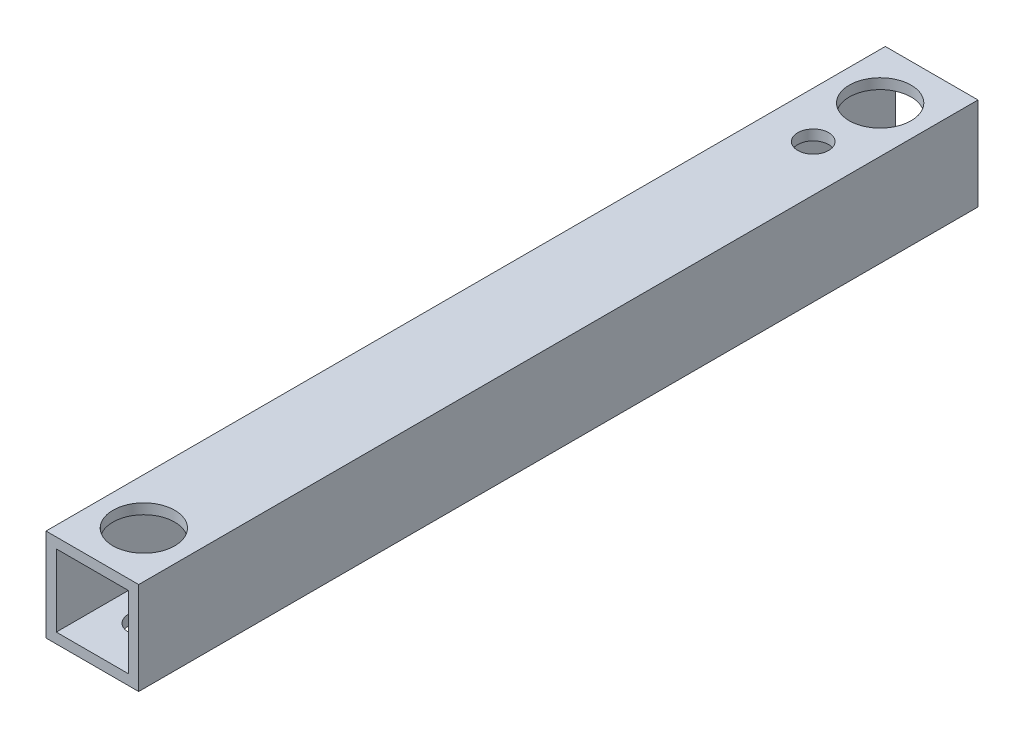
from build123d import *

# Parameters (mm, degrees)
SKETCH_1_W          = 9
SKETCH_1_H          = 9
EXTRUDE_1_DEPTH     = 81.5
SKETCH_2_W          = 7
SKETCH_2_H          = 7
CUT_EXTRUDE_1_DEPTH = 101.5
SKETCH_3_R          = 3
SKETCH_3_R_2        = 1.5
CUT_EXTRUDE_2_DEPTH = 111.5
SKETCH_4_R          = 3
CUT_EXTRUDE_3_DEPTH = 1


with BuildPart() as part:
    # ｽｹｯﾁ1 → ﾎﾞｽ - 押し出し1 (new body)
    with BuildSketch(Plane.XY):
        Rectangle(SKETCH_1_W, SKETCH_1_H)
    extrude(amount=EXTRUDE_1_DEPTH)

    # ｽｹｯﾁ2 → ｶｯﾄ - 押し出し1 (cut)
    with BuildSketch(Plane.XY.offset(81.5)):
        Rectangle(SKETCH_2_W, SKETCH_2_H)
    extrude(amount=-CUT_EXTRUDE_1_DEPTH, mode=Mode.SUBTRACT)

    # ｽｹｯﾁ3 → ｶｯﾄ - 押し出し2 (cut)
    with BuildSketch(Plane(origin=(0, 4.5, 0), x_dir=(1, 0, 0), z_dir=(0, 1, 0))):
        with Locations((0, -5)):
            Circle(SKETCH_3_R)
        with Locations((0, -11.5)):
            Circle(SKETCH_3_R_2)
        with Locations((0, -76.5)):
            Circle(SKETCH_3_R_2)
    extrude(amount=-CUT_EXTRUDE_2_DEPTH, mode=Mode.SUBTRACT)

    # ｽｹｯﾁ4 → ｶｯﾄ - 押し出し3 (cut)
    with BuildSketch(Plane(origin=(0, 4.5, 0), x_dir=(1, 0, 0), z_dir=(0, 1, 0))):
        with Locations((0, -76.5)):
            Circle(SKETCH_4_R)
    extrude(amount=-CUT_EXTRUDE_3_DEPTH, mode=Mode.SUBTRACT)


solid = part.part
